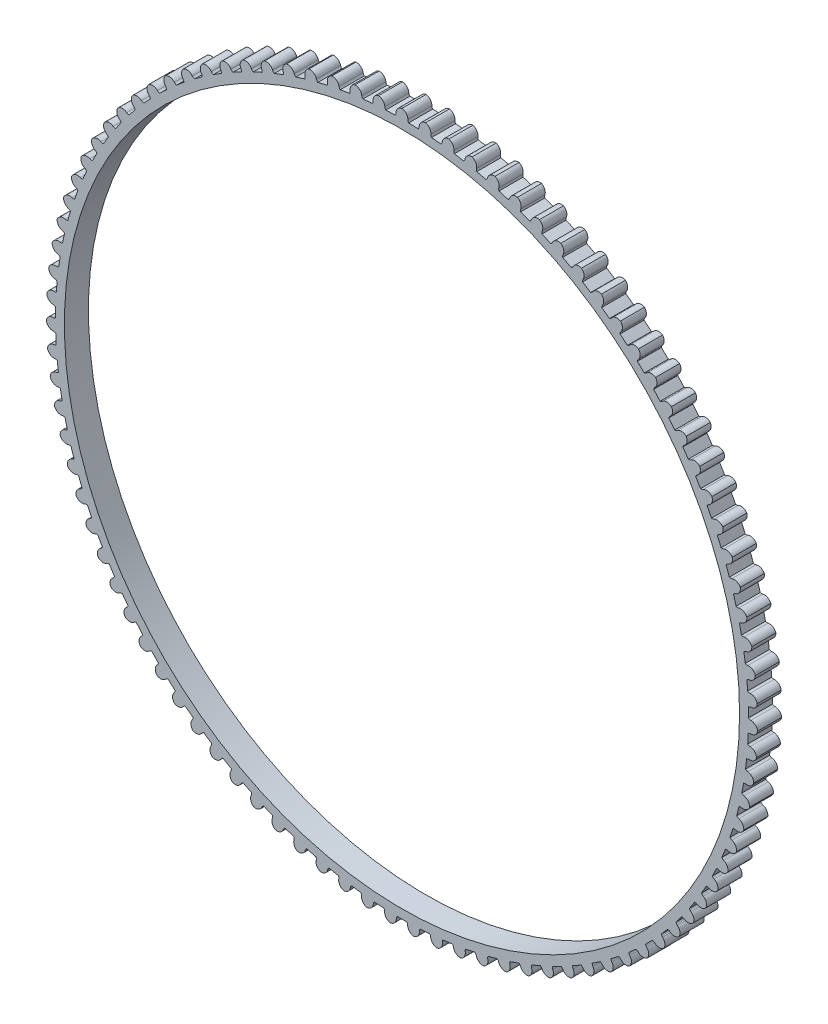
from build123d import *

# Parameters (mm, degrees)
SKETCH1_R      = 44.577
EXTRUDE1_DEPTH = 3.175


with BuildPart() as part:
    # Sketch1 → Extrude1 (new body)
    with BuildSketch(Plane.XY):
        with BuildLine():
            ThreePointArc((1.512467656, 45.720390011), (1.196213111, 45.729757219), (0.879901343, 45.736936876))
            ThreePointArc((0.879901343, 45.736936876), (0.802731173, 45.892155239), (0.777675809, 46.063678427))
            ThreePointArc((0.777675809, 46.063678427), (0.559737338, 46.661659663), (0, 46.9646))
            ThreePointArc((0, 46.9646), (-0.559737396, 46.661659691), (-0.777675895, 46.063678426))
            ThreePointArc((-0.777675895, 46.063678426), (-0.802731266, 45.892155234), (-0.879901451, 45.736936874))
            ThreePointArc((-0.879901451, 45.736936874), (-1.196213165, 45.729757218), (-1.512467656, 45.720390011))
            ThreePointArc((-1.512467656, 45.720390011), (-1.828679241, 45.708834522), (-2.144803332, 45.695092076))
            ThreePointArc((-2.144803332, 45.695092076), (-2.232063251, 45.844870852), (-2.268399903, 46.014363103))
            ThreePointArc((-2.268399903, 46.014363103), (-2.525382809, 46.596633248), (-3.103917856, 46.861917877))
            ThreePointArc((-3.103917856, 46.861917877), (-3.642409955, 46.522646537), (-3.820351029, 45.911568999))
            ThreePointArc((-3.820351029, 45.911568999), (-3.834015551, 45.738764897), (-3.900758541, 45.578785679))
            ThreePointArc((-3.900758541, 45.578785679), (-4.215933462, 45.550713784), (-4.53090667, 45.520462497))
            ThreePointArc((-4.53090667, 45.520462497), (-4.845633899, 45.488036375), (-5.160129329, 45.453434265))
            ThreePointArc((-5.160129329, 45.453434265), (-5.257097432, 45.59711851), (-5.304556481, 45.763838676))
            ThreePointArc((-5.304556481, 45.763838676), (-5.5994601, 46.327851612), (-6.19426307, 46.55432051))
            ThreePointArc((-6.19426307, 46.55432051), (-6.709155184, 46.180201686), (-6.84632074, 45.558699963))
            ThreePointArc((-6.84632074, 45.558699963), (-6.848534662, 45.385370578), (-6.904558608, 45.221330051))
            ThreePointArc((-6.904558608, 45.221330051), (-7.21718915, 45.172489437), (-7.529474384, 45.121487527))
            ThreePointArc((-7.529474384, 45.121487527), (-7.84137044, 45.068331795), (-8.152891393, 45.013020151))
            ThreePointArc((-8.152891393, 45.013020151), (-8.259143664, 45.14998157), (-8.317517582, 45.313200628))
            ThreePointArc((-8.317517582, 45.313200628), (-8.649052376, 45.856490068), (-9.257522347, 46.043152945))
            ThreePointArc((-9.257522347, 46.043152945), (-9.746562983, 45.635822564), (-9.842353232, 45.006614323))
            ThreePointArc((-9.842353232, 45.006614323), (-9.833106874, 44.833517582), (-9.878166796, 44.666133053))
            ThreePointArc((-9.878166796, 44.666133053), (-10.186885907, 44.596737287), (-10.495117623, 44.525207773))
            ThreePointArc((-10.495117623, 44.525207773), (-10.802818664, 44.451554867), (-11.110002937, 44.375775553))
            ThreePointArc((-11.110002937, 44.375775553), (-11.225074761, 44.505415248), (-11.294108295, 44.664419482))
            ThreePointArc((-11.294108295, 44.664419482), (-11.660824547, 45.184609761), (-12.280300835, 45.330650388))
            ThreePointArc((-12.280300835, 45.330650388), (-12.741351542, 44.891889601), (-12.795347618, 44.25772621))
            ThreePointArc((-12.795347618, 44.25772621), (-12.774681411, 44.08561902), (-12.808580274, 43.91562242))
            ThreePointArc((-12.808580274, 43.91562242), (-13.112038003, 43.825974953), (-13.414868382, 43.734230615))
            ThreePointArc((-13.414868382, 43.734230615), (-13.717028911, 43.640402599), (-14.018533265, 43.544486979))
            ThreePointArc((-14.018533265, 43.544486979), (-14.141921462, 43.66623807), (-14.221312746, 43.820332194))
            ThreePointArc((-14.221312746, 43.820332194), (-14.6216069, 44.315148652), (-15.249380691, 44.41992843))
            ThreePointArc((-15.249380691, 44.41992843), (-15.680425414, 43.951655827), (-15.692391205, 43.315310321))
            ThreePointArc((-15.692391205, 43.315310321), (-15.660395517, 43.144945264), (-15.682985089, 42.973079944))
            ThreePointArc((-15.682985089, 42.973079944), (-15.979854493, 42.863572781), (-16.275959335, 42.752014793))
            ThreePointArc((-16.275959335, 42.752014793), (-16.57125808, 42.638421955), (-16.865764114, 42.522789443))
            ThreePointArc((-16.865764114, 42.522789443), (-16.99692914, 42.636119542), (-17.086331015, 42.784629744))
            ThreePointArc((-17.086331015, 42.784629744), (-17.518452685, 43.251908673), (-18.151778886, 43.314969427))
            ThreePointArc((-18.151778886, 43.314969427), (-18.550932774, 42.819232645), (-18.520815957, 42.183487602))
            ThreePointArc((-18.520815957, 42.183487602), (-18.477630697, 42.015609639), (-18.488812201, 41.842627123))
            ThreePointArc((-18.488812201, 41.842627123), (-18.777795146, 41.713739111), (-19.06587966, 41.582855289))
            ThreePointArc((-19.06587966, 41.582855289), (-19.353025355, 41.44999434), (-19.639245268, 41.315150568))
            ThreePointArc((-19.639245268, 41.315150568), (-19.77761357, 41.419564113), (-19.876635106, 41.561840993))
            ThreePointArc((-19.876635106, 41.561840993), (-20.338694734, 41.999539103), (-20.97480397, 42.020605083))
            ThreePointArc((-20.97480397, 42.020605083), (-21.340321625, 41.499571853), (-21.268253894, 40.867207224))
            ThreePointArc((-21.268253894, 40.867207224), (-21.2140679, 40.702550444), (-21.213792442, 40.52920714))
            ThreePointArc((-21.213792442, 40.52920714), (-21.493625278, 40.381501874), (-21.772429743, 40.231864538))
            ThreePointArc((-21.772429743, 40.231864538), (-22.050166773, 40.080316446), (-22.326849, 39.926851052))
            ThreePointArc((-22.326849, 39.926851052), (-22.471815529, 40.021891468), (-22.580023729, 40.157312886))
            ThreePointArc((-22.580023729, 40.157312886), (-23.070000847, 40.563516234), (-23.706111573, 40.542495326))
            ThreePointArc((-23.706111573, 40.542495326), (-24.03639468, 39.998443993), (-23.922691168, 39.372224947))
            ThreePointArc((-23.922691168, 39.372224947), (-23.857741382, 39.211509352), (-23.846010165, 39.038563246))
            ThreePointArc((-23.846010165, 39.038563246), (-24.115469255, 38.872686603), (-24.383774531, 38.704950081))
            ThreePointArc((-24.383774531, 38.704950081), (-24.650888422, 38.535377527), (-24.916823101, 38.363961575))
            ThreePointArc((-24.916823101, 38.363961575), (-25.067753956, 38.449213274), (-25.184675654, 38.577187068))
            ThreePointArc((-25.184675654, 38.577187068), (-25.700427715, 38.95011943), (-26.333758382, 38.887103551))
            ThreePointArc((-26.333758382, 38.887103551), (-26.627362697, 38.322413114), (-26.4725206, 37.705077948))
            ThreePointArc((-26.4725206, 37.705077948), (-26.397091031, 37.549006307), (-26.373955354, 37.377213649))
            ThreePointArc((-26.373955354, 37.377213649), (-26.631862422, 37.193890965), (-26.888495277, 37.008788725))
            ThreePointArc((-26.888495277, 37.008788725), (-27.143818009, 36.821933206), (-27.397842275, 36.633316255))
            ThreePointArc((-27.397842275, 36.633316255), (-27.554077473, 36.708406454), (-27.679201399, 36.828373026))
            ThreePointArc((-27.679201399, 36.828373026), (-28.218473152, 37.166403664), (-28.846254366, 37.061668368))
            ThreePointArc((-28.846254366, 37.061668368), (-29.101896031, 36.478808074), (-28.906592435, 35.873056237))
            ThreePointArc((-28.906592435, 35.873056237), (-28.821012918, 35.722311011), (-28.786573946, 35.552423006))
            ThreePointArc((-28.786573946, 35.552423006), (-29.03180123, 35.352455905), (-29.275639475, 35.150797352))
            ThreePointArc((-29.275639475, 35.150797352), (-29.518054586, 34.947475941), (-29.759057655, 34.742482764))
            ThreePointArc((-29.759057655, 34.742482764), (-29.919914021, 34.807083113), (-30.05269304, 34.91851788))
            ThreePointArc((-30.05269304, 34.91851788), (-30.613126386, 35.220168671), (-31.232613019, 35.074171938))
            ThreePointArc((-31.232613019, 35.074171938), (-31.449174179, 34.475690487), (-31.214263096, 33.884170778))
            ThreePointArc((-31.214263096, 33.884170778), (-31.118907847, 33.739411138), (-31.073316175, 33.572170663))
            ThreePointArc((-31.073316175, 33.572170663), (-31.304791358, 33.35643355), (-31.53476875, 33.139100486))
            ThreePointArc((-31.53476875, 33.139100486), (-31.76321622, 32.920202255), (-31.990144248, 32.699729236))
            ThreePointArc((-31.990144248, 32.699729236), (-32.154918396, 32.753557253), (-32.2947719, 32.855972939))
            ThreePointArc((-32.2947719, 32.855972939), (-32.873916207, 33.119924842), (-33.482399403, 32.933305079))
            ThreePointArc((-33.482399403, 32.933305079), (-33.65893309, 32.321819478), (-33.385441727, 31.747118462))
            ThreePointArc((-33.385441727, 31.747118462), (-33.280727711, 31.608977404), (-33.224182699, 31.44511576))
            ThreePointArc((-33.224182699, 31.44511576), (-33.440893599, 31.214551999), (-33.656004506, 30.982494765))
            ThreePointArc((-33.656004506, 30.982494765), (-33.869485392, 30.748976901), (-34.08134608, 30.513988112))
            ThreePointArc((-34.08134608, 30.513988112), (-34.249317496, 30.556808421), (-34.39563394, 30.649757189))
            ThreePointArc((-34.39563394, 30.649757189), (-34.990956757, 30.874856009), (-35.585775772, 30.648429256))
            ThreePointArc((-35.585775772, 30.648429256), (-35.72151005, 30.026613376), (-35.410634316, 29.471244075))
            ThreePointArc((-35.410634316, 29.471244075), (-35.297019421, 29.340325655), (-35.229768325, 29.180559366))
            ThreePointArc((-35.229768325, 29.180559366), (-35.43076732, 28.936177154), (-35.630071116, 28.690410478))
            ThreePointArc((-35.630071116, 28.690410478), (-35.827651922, 28.443294094), (-36.023518857, 28.194817082))
            ThreePointArc((-36.023518857, 28.194817082), (-36.193953044, 28.226442441), (-36.346092624, 28.309517849))
            ThreePointArc((-36.346092624, 28.309517849), (-36.954990756, 28.494779286), (-37.533544599, 28.22953565))
            ThreePointArc((-37.533544599, 28.22953565), (-37.627885936, 27.600108533), (-37.28098521, 27.066499436))
            ThreePointArc((-37.28098521, 27.066499436), (-37.158966245, 26.943376127), (-37.081303138, 26.788403811))
            ThreePointArc((-37.081303138, 26.788403811), (-37.265711311, 26.531271768), (-37.448336492, 26.272870326))
            ThreePointArc((-37.448336492, 26.272870326), (-37.629153246, 26.013236), (-37.808169952, 25.752357291))
            ThreePointArc((-37.808169952, 25.752357291), (-37.980321644, 25.77264941), (-38.137619093, 25.84548819))
            ThreePointArc((-38.137619093, 25.84548819), (-38.757429984, 25.990102143), (-39.317188785, 25.687201467))
            ThreePointArc((-39.317188785, 25.687201467), (-39.369724651, 25.052915439), (-38.988315842, 24.543399881))
            ThreePointArc((-38.988315842, 24.543399881), (-38.858426365, 24.428610071), (-38.770690847, 24.279109382))
            ThreePointArc((-38.770690847, 24.279109382), (-38.937701828, 24.010351882), (-39.10284982, 23.740445597))
            ThreePointArc((-39.10284982, 23.740445597), (-39.266111857, 23.469428643), (-39.427495539, 23.197288993))
            ThreePointArc((-39.427495539, 23.197288993), (-39.600611962, 23.20615914), (-39.762379458, 23.268442787))
            ThreePointArc((-39.762379458, 23.268442787), (-40.390392831, 23.371776897), (-40.928908908, 23.032543688))
            ThreePointArc((-40.928908908, 23.032543688), (-40.939409577, 22.396172319), (-40.525160489, 21.912978284))
            ThreePointArc((-40.525160489, 21.912978284), (-40.387968473, 21.807023919), (-40.29054419, 21.663648586))
            ThreePointArc((-40.29054419, 21.663648586), (-40.439427683, 21.384440836), (-40.586376335, 21.104209939))
            ThreePointArc((-40.586376335, 21.104209939), (-40.731369751, 20.822995446), (-40.874414721, 20.540784854))
            ThreePointArc((-40.874414721, 20.540784854), (-41.047738879, 20.538194241), (-41.213269054, 20.589650405))
            ThreePointArc((-41.213269054, 20.589650405), (-41.846738767, 20.651252817), (-42.361657327, 20.277170456))
            ThreePointArc((-42.361657327, 20.277170456), (-42.330076882, 19.641496437), (-41.884798921, 19.186736808))
            ThreePointArc((-41.884798921, 19.186736808), (-41.740904271, 19.090081199), (-41.634217234, 18.953458166))
            ThreePointArc((-41.634217234, 18.953458166), (-41.764322209, 18.665021071), (-41.892428953, 18.375690941))
            ThreePointArc((-41.892428953, 18.375690941), (-42.018519729, 18.085508588), (-42.142600486, 17.794461088))
            ThreePointArc((-42.142600486, 17.794461088), (-42.315374479, 17.780421045), (-42.48394351, 17.82082472))
            ThreePointArc((-42.48394351, 17.82082472), (-43.120099562, 17.840426062), (-43.609168996, 17.433130317))
            ThreePointArc((-43.609168996, 17.433130317), (-43.53564553, 16.800933288), (-43.061285783, 16.376596614))
            ThreePointArc((-43.061285783, 16.376596614), (-42.911317715, 16.289662411), (-42.79583444, 16.160389096))
            ThreePointArc((-42.79583444, 16.160389096), (-42.906591981, 15.863983918), (-43.015296638, 15.566819723))
            ThreePointArc((-43.015296638, 15.566819723), (-43.121933412, 15.268938403), (-43.226507383, 14.970326671))
            ThreePointArc((-43.226507383, 14.970326671), (-43.397975712, 14.944898591), (-43.568846491, 14.974073103))
            ThreePointArc((-43.568846491, 14.974073103), (-44.204907133, 14.951587664), (-44.665988865, 14.512859534))
            ThreePointArc((-44.665988865, 14.512859534), (-44.550843878, 13.886903933), (-44.0494766, 13.494845729))
            ThreePointArc((-44.0494766, 13.494845729), (-43.894090885, 13.418013075), (-43.770316351, 13.296654756))
            ThreePointArc((-43.770316351, 13.296654756), (-43.861242143, 12.9935776), (-43.950069376, 12.689878762))
            ThreePointArc((-43.950069376, 12.689878762), (-44.036785852, 12.385601036), (-44.121395761, 12.080730825))
            ThreePointArc((-44.121395761, 12.080730825), (-44.29080864, 12.044025898), (-44.463233992, 12.061843674))
            ThreePointArc((-44.463233992, 12.061843674), (-45.096417893, 11.997369777), (-45.52749573, 11.529127709))
            ThreePointArc((-45.52749573, 11.529127709), (-45.371232721, 10.91215068), (-44.845050263, 10.554085318))
            ThreePointArc((-44.845050263, 10.554085318), (-44.684926364, 10.487690181), (-44.553401805, 10.374777528))
            ThreePointArc((-44.553401805, 10.374777528), (-44.624098253, 10.066353674), (-44.692659643, 9.75744819))
            ThreePointArc((-44.692659643, 9.75744819), (-44.759076631, 9.448104586), (-44.823352501, 9.138309017))
            ThreePointArc((-44.823352501, 9.138309017), (-44.989969131, 9.090487744), (-45.163195084, 9.096870872))
            ThreePointArc((-45.163195084, 9.096870872), (-45.790733491, 8.990690445), (-46.189922439, 8.494981943))
            ThreePointArc((-46.189922439, 8.494981943), (-45.993224707, 7.889681369), (-45.444527931, 7.567174577))
            ThreePointArc((-45.444527931, 7.567174577), (-45.28036603, 7.511507287), (-45.141666569, 7.407534038))
            ThreePointArc((-45.141666569, 7.407534038), (-45.191824535, 7.095112143), (-45.239820281, 6.78235078))
            ThreePointArc((-45.239820281, 6.78235078), (-45.285647357, 6.469293979), (-45.329308126, 6.155927709))
            ThreePointArc((-45.329308126, 6.155927709), (-45.492399934, 6.097199201), (-45.665669015, 6.092119768))
            ThreePointArc((-45.665669015, 6.092119768), (-46.284817863, 5.944697111), (-46.650372371, 5.423689781))
            ThreePointArc((-46.650372371, 5.423689781), (-46.414100025, 4.832712488), (-45.845288242, 4.547174508))
            ThreePointArc((-45.845288242, 4.547174508), (-45.677806176, 4.502478482), (-45.532538311, 4.407899286))
            ThreePointArc((-45.532538311, 4.407899286), (-45.561938468, 4.092845493), (-45.589158695, 3.777595876))
            ThreePointArc((-45.589158695, 3.777595876), (-45.61419547, 3.462194795), (-45.63705022, 3.146628095))
            ThreePointArc((-45.63705022, 3.146628095), (-45.795904047, 3.077249156), (-45.968458595, 3.060729374))
            ThreePointArc((-45.968458595, 3.060729374), (-46.576510503, 2.872709129), (-46.906832093, 2.328681205))
            ThreePointArc((-46.906832093, 2.328681205), (-46.632018292, 1.754611385), (-46.045578771, 1.507290801))
            ThreePointArc((-46.045578771, 1.507290801), (-45.875508898, 1.473761485), (-45.724307848, 1.388989913))
            ThreePointArc((-45.724307848, 1.388989913), (-45.732821636, 1.072681871), (-45.739147319, 0.756322506))
            ThreePointArc((-45.739147319, 0.756322506), (-45.743284311, 0.439956314), (-45.745233105, 0.123569077))
            ThreePointArc((-45.745233105, 0.123569077), (-45.899154323, 0.043843084), (-46.070239801, 0.015955189))
            ThreePointArc((-46.070239801, 0.015955189), (-46.664535913, -0.211840479), (-46.958180174, -0.776510102))
            ThreePointArc((-46.958180174, -0.776510102), (-46.646026608, -1.331162186), (-46.044523701, -1.539183906))
            ThreePointArc((-46.044523701, -1.539183906), (-45.872609691, -1.561399896), (-45.716136621, -1.635993161))
            ThreePointArc((-45.716136621, -1.635993161), (-45.703726811, -1.952172317), (-45.689130288, -2.26825807))
            ThreePointArc((-45.689130288, -2.26825807), (-45.67234941, -2.584205983), (-45.653383725, -2.900030277))
            ThreePointArc((-45.653383725, -2.900030277), (-45.801699277, -2.989754702), (-45.97056757, -3.028888763))
            ThreePointArc((-45.97056757, -3.028888763), (-46.548509181, -3.295463763), (-46.80419208, -3.878305928))
            ThreePointArc((-46.80419208, -3.878305928), (-46.456063718, -4.411114925), (-45.842127644, -4.578928152))
            ThreePointArc((-45.842127644, -4.578928152), (-45.669121235, -4.589733673), (-45.50806036, -4.653822452))
            ThreePointArc((-45.50806036, -4.653822452), (-45.474781218, -4.968490151), (-45.439326316, -5.28292013))
            ThreePointArc((-45.439326316, -5.28292013), (-45.401700945, -5.597068206), (-45.361903714, -5.910948537))
            ThreePointArc((-45.361903714, -5.910948537), (-45.503965053, -6.010279052), (-45.669877744, -6.060488156))
            ThreePointArc((-45.669877744, -6.060488156), (-46.228937662, -6.364676822), (-46.445541164, -6.963142909))
            ThreePointArc((-46.445541164, -6.963142909), (-46.062960282, -7.47177898), (-45.439275627, -7.598649911))
            ThreePointArc((-45.439275627, -7.598649911), (-45.265933331, -7.597997712), (-45.10098893, -7.651301762))
            ThreePointArc((-45.10098893, -7.651301762), (-45.046985976, -7.963082042), (-44.990827731, -8.274481325))
            ThreePointArc((-44.990827731, -8.274481325), (-44.932522393, -8.585455873), (-44.87206764, -8.896019722))
            ThreePointArc((-44.87206764, -8.896019722), (-45.007253568, -9.004521981), (-45.169485163, -9.065586575))
            ThreePointArc((-45.169485163, -9.065586575), (-45.70721876, -9.406058768), (-45.883795713, -10.017531838))
            ThreePointArc((-45.883795713, -10.017531838), (-45.468435241, -10.499770846), (-44.837729219, -10.585144707))
            ThreePointArc((-44.837729219, -10.585144707), (-44.664809018, -10.573037641), (-44.496702352, -10.615323876))
            ThreePointArc((-44.496702352, -10.615323876), (-44.422211727, -10.922853402), (-44.345595705, -11.229860318))
            ThreePointArc((-44.345595705, -11.229860318), (-44.266865354, -11.536301526), (-44.186017431, -11.842190877))
            ThreePointArc((-44.186017431, -11.842190877), (-44.313736814, -11.959390427), (-44.471577916, -12.031043492))
            ThreePointArc((-44.471577916, -12.031043492), (-44.985633821, -12.406310413), (-45.121412098, -13.028116649))
            ThreePointArc((-45.121412098, -13.028116649), (-44.675088301, -13.481849886), (-44.040118829, -13.525353359))
            ThreePointArc((-44.040118829, -13.525353359), (-43.868376859, -13.501844366), (-43.697843015, -13.53292788))
            ThreePointArc((-43.697843015, -13.53292788), (-43.603190449, -13.834861902), (-43.506451671, -14.13613399))
            ThreePointArc((-43.506451671, -14.13613399), (-43.407640576, -14.436701868), (-43.30675301, -14.736579145))
            ThreePointArc((-43.30675301, -14.736579145), (-43.426447365, -14.861963501), (-43.579207774, -14.943891716))
            ThreePointArc((-43.579207774, -14.943891716), (-44.067338151, -15.352312419), (-44.161724029, -15.98173282))
            ThreePointArc((-44.161724029, -15.98173282), (-43.686388567, -16.404976227), (-43.049932205, -16.406419082))
            ThreePointArc((-43.049932205, -16.406419082), (-42.880119451, -16.371610961), (-42.707904129, -16.391355834))
            ThreePointArc((-42.707904129, -16.391355834), (-42.593503513, -16.686374072), (-42.477064994, -16.980593944))
            ThreePointArc((-42.477064994, -16.980593944), (-42.35860523, -17.273974186), (-42.238119177, -17.566528101))
            ThreePointArc((-42.238119177, -17.566528101), (-42.34926511, -17.69954899), (-42.496276845, -17.791394104))
            ThreePointArc((-42.496276845, -17.791394104), (-42.956347224, -18.231182669), (-43.008927977, -18.865464941))
            ThreePointArc((-43.008927977, -18.865464941), (-42.506659372, -19.256367781), (-41.871499181, -19.215743708))
            ThreePointArc((-41.871499181, -19.215743708), (-41.70435819, -19.169788667), (-41.531214445, -19.178108559))
            ThreePointArc((-41.531214445, -19.178108559), (-41.397566023, -19.464920973), (-41.261936919, -19.750802082))
            ThreePointArc((-41.261936919, -19.750802082), (-41.12434648, -20.03571181), (-40.984788797, -20.319663099))
            ThreePointArc((-40.984788797, -20.319663099), (-41.086900295, -20.459738855), (-41.22752051, -20.561099253))
            ThreePointArc((-41.22752051, -20.561099253), (-41.65751912, -21.030332596), (-41.668064826, -21.666703183))
            ThreePointArc((-41.668064826, -21.666703183), (-41.14105937, -22.023556139), (-40.509972745, -21.941042777))
            ThreePointArc((-40.509972745, -21.941042777), (-40.346234382, -21.884141764), (-40.172919327, -21.881000294))
            ThreePointArc((-40.172919327, -21.881000294), (-40.020607511, -22.158352728), (-39.866380893, -22.434644987))
            ThreePointArc((-39.866380893, -22.434644987), (-39.710261428, -22.709838364), (-39.552242362, -22.983945381))
            ThreePointArc((-39.552242362, -22.983945381), (-39.644872918, -23.130463487), (-39.778486717, -23.240895946))
            ThreePointArc((-39.778486717, -23.240895946), (-40.176533284, -23.73752223), (-40.14499783, -24.373198445))
            ThreePointArc((-40.14499783, -24.373198445), (-39.595559984, -24.694441089), (-38.971306506, -24.570399248))
            ThreePointArc((-38.971306506, -24.570399248), (-38.811686756, -24.502801078), (-38.638958255, -24.488211983))
            ThreePointArc((-38.638958255, -24.488211983), (-38.468649064, -24.754891644), (-38.296499326, -25.020386898))
            ThreePointArc((-38.296499326, -25.020386898), (-38.122533506, -25.284660573), (-37.946744036, -25.547724717))
            ThreePointArc((-37.946744036, -25.547724717), (-38.029488599, -25.700044488), (-38.155511723, -25.819066114))
            ThreePointArc((-38.155511723, -25.819066114), (-38.519865691, -26.340913718), (-38.446386972, -26.973115911))
            ThreePointArc((-38.446386972, -26.973115911), (-37.876919288, -27.257343531), (-37.262228659, -27.092315614))
            ThreePointArc((-37.262228659, -27.092315614), (-37.1074255, -27.014315877), (-36.936038849, -26.988342952))
            ThreePointArc((-36.936038849, -26.988342952), (-36.748477003, -27.243183718), (-36.559156912, -27.496721023))
            ThreePointArc((-36.559156912, -27.496721023), (-36.368105444, -27.748919394), (-36.175314253, -27.999790354))
            ThreePointArc((-36.175314253, -27.999790354), (-36.247811003, -28.157245733), (-36.365692385, -28.284336076))
            ThreePointArc((-36.365692385, -28.284336076), (-36.694760526, -28.829123093), (-36.579659846, -29.455086805))
            ThreePointArc((-36.579659846, -29.455086805), (-35.992652461, -29.701056545), (-35.390212566, -29.495764178))
            ThreePointArc((-35.390212566, -29.495764178), (-35.240902913, -29.407703946), (-35.071607543, -29.370460764))
            ThreePointArc((-35.071607543, -29.370460764), (-34.867613203, -29.612348281), (-34.661950607, -29.852818983))
            ThreePointArc((-34.661950607, -29.852818983), (-34.454648911, -30.091839252), (-34.245699025, -30.329420032))
            ThreePointArc((-34.245699025, -30.329420032), (-34.307630952, -30.491322507), (-34.416855126, -30.625925833))
            ThreePointArc((-34.416855126, -30.625925833), (-34.709198509, -31.191270048), (-34.552979175, -31.808258099))
            ThreePointArc((-34.552979175, -31.808258099), (-33.950998923, -32.014894396), (-33.363444079, -31.77023527))
            ThreePointArc((-33.363444079, -31.77023527), (-33.220280825, -31.672499608), (-33.053817022, -31.624149024))
            ThreePointArc((-33.053817022, -31.624149024), (-32.834282201, -31.852025579), (-32.613176412, -32.078378162))
            ThreePointArc((-32.613176412, -32.078378162), (-32.390530965, -32.303175153), (-32.166336069, -32.526426872))
            ThreePointArc((-32.166336069, -32.526426872), (-32.21743236, -32.692068486), (-32.317521717, -32.833596208))
            ThreePointArc((-32.317521717, -32.833596208), (-32.571861999, -33.417025515), (-32.375207118, -34.022339973))
            ThreePointArc((-32.375207118, -34.022339973), (-31.760886306, -34.18873926), (-31.19078574, -33.905783207))
            ThreePointArc((-31.19078574, -33.905783207), (-31.054394901, -33.798799489), (-30.891490568, -33.739552926))
            ThreePointArc((-30.891490568, -33.739552926), (-30.657375238, -33.952422074), (-30.421793093, -34.163666755))
            ThreePointArc((-30.421793093, -34.163666755), (-30.184777468, -34.373257488), (-29.946317909, -34.581203924))
            ThreePointArc((-29.946317909, -34.581203924), (-29.986355134, -34.749860368), (-30.076872008, -34.897693621))
            ThreePointArc((-30.076872008, -34.897693621), (-30.292097024, -35.496656832), (-30.055866517, -36.087650811))
            ThreePointArc((-30.055866517, -36.087650811), (-29.431891413, -36.213085465), (-28.881738031, -35.893069781))
            ThreePointArc((-28.881738031, -35.893069781), (-28.75271601, -35.777305818), (-28.594083486, -35.707422348))
            ThreePointArc((-28.594083486, -35.707422348), (-28.346411373, -35.904353266), (-28.097383014, -36.099566326))
            ThreePointArc((-28.097383014, -36.099566326), (-27.84703362, -36.293034314), (-27.595352121, -36.48476617))
            ThreePointArc((-27.595352121, -36.48476617), (-27.624155207, -36.655699951), (-27.704703791, -36.809192299))
            ThreePointArc((-27.704703791, -36.809192299), (-27.879872416, -37.4210703), (-27.60509926, -37.995159534))
            ThreePointArc((-27.60509926, -37.995159534), (-26.974198349, -38.079081062), (-26.44639783, -37.723405093))
            ThreePointArc((-26.44639783, -37.723405093), (-26.325308807, -37.599367093), (-26.171641752, -37.519152298))
            ThreePointArc((-26.171641752, -37.519152298), (-25.911495863, -37.699283856), (-25.650110229, -37.877611678))
            ThreePointArc((-25.650110229, -37.877611678), (-25.387521779, -38.054110935), (-25.123718879, -38.228789817))
            ThreePointArc((-25.123718879, -38.228789817), (-25.141161877, -38.401253486), (-25.211389953, -38.559733745))
            ThreePointArc((-25.211389953, -38.559733745), (-25.345736219, -39.18185095), (-25.033621927, -39.736525092))
            ThreePointArc((-25.033621927, -39.736525092), (-24.398553977, -39.778566526), (-23.89541426, -39.388785552))
            ThreePointArc((-23.89541426, -39.388785552), (-23.782787727, -39.257015901), (-23.634758088, -39.166820541))
            ThreePointArc((-23.634758088, -39.166820541), (-23.363275975, -39.329365071), (-23.090676037, -39.490027872))
            ThreePointArc((-23.090676037, -39.490027872), (-22.816996765, -39.648786612), (-22.542226006, -39.805648693))
            ThreePointArc((-22.542226006, -39.805648693), (-22.548232643, -39.97888811), (-22.607833122, -40.141663287))
            ThreePointArc((-22.607833122, -40.141663287), (-22.700769567, -40.771299334), (-22.352678935, -41.304132936))
            ThreePointArc((-22.352678935, -41.304132936), (-21.716220938, -41.30411044), (-21.239942124, -40.881928875))
            ThreePointArc((-21.239942124, -40.881928875), (-21.136270567, -40.743003768), (-20.994525641, -40.643222243))
            ThreePointArc((-20.994525641, -40.643222243), (-20.712894426, -40.787468978), (-20.430272195, -40.929764221))
            ThreePointArc((-20.430272195, -40.929764221), (-20.146698829, -41.070088233), (-19.862161715, -41.208447595))
            ThreePointArc((-19.862161715, -41.208447595), (-19.856705725, -41.381705228), (-19.905417988, -41.548063548))
            ThreePointArc((-19.905417988, -41.548063548), (-19.956538226, -42.182465201), (-19.573993365, -42.691128316))
            ThreePointArc((-19.573993365, -42.691128316), (-18.938928389, -42.649041989), (-18.491593125, -42.196305924))
            ThreePointArc((-18.491593125, -42.196305924), (-18.397329874, -42.050832846), (-18.262489475, -41.941901475))
            ThreePointArc((-18.262489475, -41.941901475), (-17.971940659, -42.067219662), (-17.68053197, -42.190525126))
            ThreePointArc((-17.68053197, -42.190525126), (-17.388304505, -42.311800808), (-17.095245245, -42.43105244))
            ThreePointArc((-17.095245245, -42.43105244), (-17.078350485, -42.603570678), (-17.115961527, -42.772784699))
            ThreePointArc((-17.115961527, -42.772784699), (-17.125042021, -43.409177879), (-16.709715703, -43.891446254))
            ThreePointArc((-16.709715703, -43.891446254), (-16.078820726, -43.807480128), (-15.662385094, -43.326169264))
            ThreePointArc((-15.662385094, -43.326169264), (-15.577942339, -43.174784331), (-15.450596089, -43.057179444))
            ThreePointArc((-15.450596089, -43.057179444), (-15.152400169, -43.163021098), (-14.853479277, -43.2667976))
            ThreePointArc((-14.853479277, -43.2667976), (-14.55387555, -43.368494643), (-14.253575617, -43.468117089))
            ThreePointArc((-14.253575617, -43.468117089), (-14.225315964, -43.639141554), (-14.25166132, -43.810471345))
            ThreePointArc((-14.25166132, -43.810471345), (-14.218662364, -44.446073268), (-13.772370706, -44.899838065))
            ThreePointArc((-13.772370706, -44.899838065), (-13.14840447, -44.774359303), (-12.764689438, -44.26657829))
            ThreePointArc((-12.764689438, -44.26657829), (-12.690436425, -44.109943469), (-12.571141177, -43.984179323))
            ThreePointArc((-12.571141177, -43.984179323), (-12.266602088, -44.070081624), (-11.961476099, -44.153875376))
            ThreePointArc((-11.961476099, -44.153875376), (-11.655806201, -44.235549086), (-11.349578729, -44.315106723))
            ThreePointArc((-11.349578729, -44.315106723), (-11.310077756, -44.483889567), (-11.325042225, -44.656585947))
            ThreePointArc((-11.325042225, -44.656585947), (-11.250108114, -45.288617287), (-10.774802635, -45.711894309))
            ThreePointArc((-10.774802635, -45.711894309), (-10.160493588, -45.545451597), (-9.811177043, -45.013420832))
            ThreePointArc((-9.811177043, -45.013420832), (-9.747438462, -44.852221048), (-9.636715863, -44.718847576))
            ThreePointArc((-9.636715863, -44.718847576), (-9.327165278, -44.784434897), (-9.01716843, -44.847879489))
            ThreePointArc((-9.01716843, -44.847879489), (-8.706768976, -44.909172729), (-8.395953021, -44.96831767))
            ThreePointArc((-8.395953021, -44.96831767), (-8.345383455, -45.134120849), (-8.348901602, -45.307428662))
            ThreePointArc((-8.348901602, -45.307428662), (-8.232360004, -45.933125706), (-7.730119095, -46.32406407))
            ThreePointArc((-7.730119095, -46.32406407), (-7.128153452, -46.117385219), (-6.814762868, -45.563431137))
            ThreePointArc((-6.814762868, -45.563431137), (-6.76181743, -45.398371277), (-6.660151644, -45.257971687))
            ThreePointArc((-6.660151644, -45.257971687), (-6.346943146, -45.302957231), (-6.033430977, -45.345775237))
            ThreePointArc((-6.033430977, -45.345775237), (-5.719659266, -45.386419985), (-5.405613947, -45.424893605))
            ThreePointArc((-5.405613947, -45.424893605), (-5.344196916, -45.586992105), (-5.336253356, -45.760153518))
            ThreePointArc((-5.336253356, -45.760153518), (-5.178613878, -46.376780253), (-4.65163371, -46.733670485))
            ThreePointArc((-4.65163371, -46.733670485), (-4.064643714, -46.48765925), (-3.788549468, -45.914204152))
            ThreePointArc((-3.788549468, -45.914204152), (-3.746628692, -45.746005979), (-3.654464275, -45.599194204))
            ThreePointArc((-3.654464275, -45.599194204), (-3.338967447, -45.623381259), (-3.023310865, -45.645385447))
            ThreePointArc((-3.023310865, -45.645385447), (-2.707538942, -45.665203975), (-2.391637499, -45.682838038))
            ThreePointArc((-2.391637499, -45.682838038), (-2.319641564, -45.840523043), (-2.300271032, -46.012780866))
            ThreePointArc((-2.300271032, -46.012780866), (-2.102222992, -46.61764094), (-1.552807915, -46.93892245))
            ThreePointArc((-1.552807915, -46.93892245), (-0.983360324, -46.654654576), (-0.745769705, -46.064206034))
            ThreePointArc((-0.745769705, -46.064206034), (-0.715056899, -45.893605036), (-0.632796864, -45.741023046))
            ThreePointArc((-0.632796864, -45.741023046), (-0.316391293, -45.74430585), (2.9415e-05, -45.7454))
            ThreePointArc((2.9415e-05, -45.7454), (0.316420762, -45.744305646), (0.632796972, -45.741023044))
            ThreePointArc((0.632796972, -45.741023044), (0.715056991, -45.893605037), (0.745769792, -46.064206031))
            ThreePointArc((0.745769792, -46.064206031), (0.983360381, -46.654654545), (1.552807915, -46.93892245))
            ThreePointArc((1.552807915, -46.93892245), (2.102223051, -46.617640967), (2.300271119, -46.012780863))
            ThreePointArc((2.300271119, -46.012780863), (2.319641655, -45.840523035), (2.391637606, -45.682838033))
            ThreePointArc((2.391637606, -45.682838033), (2.707568359, -45.66520223), (3.023369567, -45.645381559))
            ThreePointArc((3.023369567, -45.645381559), (3.338996838, -45.623379109), (3.654464383, -45.599194195))
            ThreePointArc((3.654464383, -45.599194195), (3.746628784, -45.746005974), (3.788549554, -45.914204144))
            ThreePointArc((3.788549554, -45.914204144), (4.064643769, -46.487659216), (4.65163371, -46.733670485))
            ThreePointArc((4.65163371, -46.733670485), (5.178613939, -46.376780276), (5.336253442, -45.760153509))
            ThreePointArc((5.336253442, -45.760153509), (5.344197007, -45.586992091), (5.405614054, -45.424893592))
            ThreePointArc((5.405614054, -45.424893592), (5.719688504, -45.3864163), (6.033489293, -45.345767477))
            ThreePointArc((6.033489293, -45.345767477), (6.34697233, -45.302953142), (6.66015175, -45.257971672))
            ThreePointArc((6.66015175, -45.257971672), (6.761817522, -45.398371266), (6.814762953, -45.563431124))
            ThreePointArc((6.814762953, -45.563431124), (7.128153504, -46.117385182), (7.730119095, -46.32406407))
            ThreePointArc((7.730119095, -46.32406407), (8.232360066, -45.933125725), (8.348901687, -45.307428647))
            ThreePointArc((8.348901687, -45.307428647), (8.345383545, -45.134120829), (8.395953127, -44.96831765))
            ThreePointArc((8.395953127, -44.96831765), (8.706797907, -44.90916712), (9.017226106, -44.847867893))
            ThreePointArc((9.017226106, -44.847867893), (9.327194127, -44.784428889), (9.636715969, -44.718847553))
            ThreePointArc((9.636715969, -44.718847553), (9.747438553, -44.852221032), (9.811177128, -45.013420812))
            ThreePointArc((9.811177128, -45.013420812), (10.160493637, -45.545451556), (10.774802635, -45.711894309))
            ThreePointArc((10.774802635, -45.711894309), (11.250108177, -45.288617302), (11.325042309, -44.656585927))
            ThreePointArc((11.325042309, -44.656585927), (11.310077845, -44.483889541), (11.349578834, -44.315106696))
            ThreePointArc((11.349578834, -44.315106696), (11.655834697, -44.235541578), (11.961532883, -44.153859993))
            ThreePointArc((11.961532883, -44.153859993), (12.266630478, -44.070073722), (12.571141281, -43.984179293))
            ThreePointArc((12.571141281, -43.984179293), (12.690436515, -44.109943447), (12.764689521, -44.266578265))
            ThreePointArc((12.764689521, -44.266578265), (13.148404517, -44.774359259), (13.772370706, -44.899838066))
            ThreePointArc((13.772370706, -44.899838066), (14.218662427, -44.446073278), (14.251661403, -43.810471319))
            ThreePointArc((14.251661403, -43.810471319), (14.225316051, -43.639141522), (14.253575719, -43.468117056))
            ThreePointArc((14.253575719, -43.468117056), (14.553903488, -43.368485268), (14.85353492, -43.266778497))
            ThreePointArc((14.85353492, -43.266778497), (15.152427975, -43.163011337), (15.45059619, -43.057179408))
            ThreePointArc((15.45059619, -43.057179408), (15.577942427, -43.174784302), (15.662385175, -43.326169234))
            ThreePointArc((15.662385175, -43.326169234), (16.07882077, -43.807480081), (16.709715703, -43.891446254))
            ThreePointArc((16.709715703, -43.891446254), (17.125042085, -43.409177885), (17.115961607, -42.772784668))
            ThreePointArc((17.115961607, -42.772784668), (17.07835057, -42.603570641), (17.095245345, -42.4310524))
            ThreePointArc((17.095245345, -42.4310524), (17.388331762, -42.311789606), (17.680586228, -42.190502388))
            ThreePointArc((17.680586228, -42.190502388), (17.971967759, -42.067208085), (18.262489574, -41.941901432))
            ThreePointArc((18.262489574, -41.941901432), (18.39732996, -42.050832812), (18.491593204, -42.196305889))
            ThreePointArc((18.491593204, -42.196305889), (18.93892843, -42.649041939), (19.573993365, -42.691128316))
            ThreePointArc((19.573993365, -42.691128316), (19.95653829, -42.182465202), (19.905418067, -41.548063511))
            ThreePointArc((19.905418067, -41.548063511), (19.856705807, -41.381705185), (19.862161813, -41.208447548))
            ThreePointArc((19.862161813, -41.208447548), (20.146725286, -41.070075255), (20.430324832, -40.929737947))
            ThreePointArc((20.430324832, -40.929737947), (20.712920701, -40.787455635), (20.994525737, -40.643222193))
            ThreePointArc((20.994525737, -40.643222193), (21.13627065, -40.743003728), (21.2399422, -40.881928834))
            ThreePointArc((21.2399422, -40.881928834), (21.716220975, -41.304110388), (22.352678935, -41.304132936))
            ThreePointArc((22.352678935, -41.304132936), (22.700769632, -40.771299332), (22.607833198, -40.141663245))
            ThreePointArc((22.607833198, -40.141663245), (22.548232722, -39.978888062), (22.5422261, -39.80564864))
            ThreePointArc((22.5422261, -39.80564864), (22.817022306, -39.648771913), (23.090726823, -39.489998176))
            ThreePointArc((23.090726823, -39.489998176), (23.363301311, -39.32935002), (23.634758181, -39.166820485))
            ThreePointArc((23.634758181, -39.166820485), (23.782787807, -39.257015856), (23.895414334, -39.388785507))
            ThreePointArc((23.895414334, -39.388785507), (24.398554011, -39.778566471), (25.033621927, -39.736525092))
            ThreePointArc((25.033621927, -39.736525092), (25.345736284, -39.181850943), (25.211390026, -38.559733699))
            ThreePointArc((25.211390026, -38.559733699), (25.141161952, -38.401253433), (25.123718969, -38.228789758))
            ThreePointArc((25.123718969, -38.228789758), (25.387546293, -38.054094581), (25.650158941, -37.877578691))
            ThreePointArc((25.650158941, -37.877578691), (25.911520149, -37.699267164), (26.171641841, -37.519152236))
            ThreePointArc((26.171641841, -37.519152236), (26.325308884, -37.599367042), (26.4463979, -37.723405042))
            ThreePointArc((26.4463979, -37.723405042), (26.974198378, -38.079081005), (27.60509926, -37.995159534))
            ThreePointArc((27.60509926, -37.995159534), (27.879872479, -37.42107029), (27.704703861, -36.809192248))
            ThreePointArc((27.704703861, -36.809192248), (27.624155279, -36.655699894), (27.595352207, -36.484766105))
            ThreePointArc((27.595352207, -36.484766105), (27.847057, -36.293016375), (28.09742944, -36.099530191))
            ThreePointArc((28.09742944, -36.099530191), (28.346434502, -35.904335005), (28.59408357, -35.707422281))
            ThreePointArc((28.59408357, -35.707422281), (28.752716083, -35.777305763), (28.881738098, -35.893069726))
            ThreePointArc((28.881738098, -35.893069726), (29.43189144, -36.213085406), (30.055866517, -36.087650811))
            ThreePointArc((30.055866517, -36.087650811), (30.292097087, -35.496656817), (30.076872075, -34.897693565))
            ThreePointArc((30.076872075, -34.897693565), (29.986355202, -34.749860305), (29.94631799, -34.581203854))
            ThreePointArc((29.94631799, -34.581203854), (30.184799612, -34.373238043), (30.421837029, -34.163627632))
            ThreePointArc((30.421837029, -34.163627632), (30.65739711, -33.952402325), (30.891490647, -33.739552853))
            ThreePointArc((30.891490647, -33.739552853), (31.054394971, -33.798799428), (31.190785803, -33.905783148))
            ThreePointArc((31.190785803, -33.905783148), (31.760886328, -34.188739199), (32.375207118, -34.022339973))
            ThreePointArc((32.375207118, -34.022339973), (32.571862061, -33.417025496), (32.317521779, -32.833596148))
            ThreePointArc((32.317521779, -32.833596148), (32.217432424, -32.692068419), (32.166336145, -32.526426797))
            ThreePointArc((32.166336145, -32.526426797), (32.390551775, -32.303154287), (32.613217665, -32.07833622))
            ThreePointArc((32.613217665, -32.07833622), (32.83430272, -31.852004428), (33.053817096, -31.624148946))
            ThreePointArc((33.053817096, -31.624148946), (33.220280891, -31.672499544), (33.363444138, -31.770235207))
            ThreePointArc((33.363444138, -31.770235207), (33.950998942, -32.014894334), (34.552979175, -31.808258099))
            ThreePointArc((34.552979175, -31.808258099), (34.70919857, -31.191270025), (34.416855184, -30.625925769))
            ThreePointArc((34.416855184, -30.625925769), (34.307631011, -30.491322437), (34.245699097, -30.329419951))
            ThreePointArc((34.245699097, -30.329419951), (34.454668296, -30.091817056), (34.661988999, -29.852774407))
            ThreePointArc((34.661988999, -29.852774407), (34.867632279, -29.612325819), (35.071607613, -29.370460681))
            ThreePointArc((35.071607613, -29.370460681), (35.240902975, -29.407703877), (35.390212621, -29.495764111))
            ThreePointArc((35.390212621, -29.495764111), (35.992652475, -29.701056482), (36.579659846, -29.455086805))
            ThreePointArc((36.579659846, -29.455086805), (36.694760584, -28.829123066), (36.365692439, -28.284336008))
            ThreePointArc((36.365692439, -28.284336008), (36.247811058, -28.157245659), (36.175314319, -27.999790269))
            ThreePointArc((36.175314319, -27.999790269), (36.36812332, -27.748895966), (36.559192274, -27.496674007))
            ThreePointArc((36.559192274, -27.496674007), (36.748494553, -27.243160045), (36.936038913, -26.988342865))
            ThreePointArc((36.936038913, -26.988342865), (37.107425557, -27.014315804), (37.262228709, -27.092315544))
            ThreePointArc((37.262228709, -27.092315544), (37.876919298, -27.257343467), (38.446386972, -26.973115911))
            ThreePointArc((38.446386972, -26.973115911), (38.519865748, -26.340913687), (38.155511772, -25.819066043))
            ThreePointArc((38.155511772, -25.819066043), (38.029488649, -25.70004441), (37.946744096, -25.547724628))
            ThreePointArc((37.946744096, -25.547724628), (38.122549794, -25.284636014), (38.296531503, -25.020337647))
            ThreePointArc((38.296531503, -25.020337647), (38.468665011, -24.754866863), (38.638958313, -24.488211892))
            ThreePointArc((38.638958313, -24.488211892), (38.811686808, -24.502801002), (38.971306551, -24.570399174))
            ThreePointArc((38.971306551, -24.570399174), (39.595559989, -24.694441024), (40.14499783, -24.373198445))
            ThreePointArc((40.14499783, -24.373198445), (40.176533339, -23.737522195), (39.778486762, -23.240895872))
            ThreePointArc((39.778486762, -23.240895872), (39.644872962, -23.130463406), (39.552242417, -22.983945288))
            ThreePointArc((39.552242417, -22.983945288), (39.710276057, -22.709812782), (39.866409744, -22.434593717))
            ThreePointArc((39.866409744, -22.434593717), (40.020621785, -22.158326947), (40.172919379, -21.8810002))
            ThreePointArc((40.172919379, -21.8810002), (40.346234428, -21.884141685), (40.509972786, -21.9410427))
            ThreePointArc((40.509972786, -21.9410427), (41.141059371, -22.023556074), (41.668064826, -21.666703183))
            ThreePointArc((41.668064826, -21.666703183), (41.657519172, -21.030332558), (41.227520549, -20.561099176))
            ThreePointArc((41.227520549, -20.561099176), (41.086900333, -20.459738771), (40.984788845, -20.319663002))
            ThreePointArc((40.984788845, -20.319663002), (41.124359387, -20.035685318), (41.261962319, -19.750749017))
            ThreePointArc((41.261962319, -19.750749017), (41.397578563, -19.464894305), (41.53121449, -19.178108461))
            ThreePointArc((41.53121449, -19.178108461), (41.704358231, -19.169788584), (41.871499217, -19.215743629))
            ThreePointArc((41.871499217, -19.215743629), (42.506659369, -19.256367717), (43.008927977, -18.865464941))
            ThreePointArc((43.008927977, -18.865464941), (42.956347274, -18.231182628), (42.496276879, -17.791394025))
            ThreePointArc((42.496276879, -17.791394025), (42.349265143, -17.699548904), (42.238119219, -17.566528001))
            ThreePointArc((42.238119219, -17.566528001), (42.358616357, -17.273946899), (42.477086831, -16.980539317))
            ThreePointArc((42.477086831, -16.980539317), (42.593514262, -16.686346633), (42.707904168, -16.391355733))
            ThreePointArc((42.707904168, -16.391355733), (42.880119486, -16.371610876), (43.049932235, -16.406419))
            ThreePointArc((43.049932235, -16.406419), (43.68638856, -16.404976163), (44.161724029, -15.98173282))
            ThreePointArc((44.161724029, -15.98173282), (44.067338198, -15.352312375), (43.579207803, -14.943891635))
            ThreePointArc((43.579207803, -14.943891635), (43.426447392, -14.861963413), (43.306753045, -14.736579042))
            ThreePointArc((43.306753045, -14.736579042), (43.407649876, -14.436673905), (43.50646985, -14.136078039))
            ThreePointArc((43.50646985, -14.136078039), (43.603199361, -13.834833813), (43.697843047, -13.532927777))
            ThreePointArc((43.697843047, -13.532927777), (43.868376889, -13.501844279), (44.040118854, -13.525353276))
            ThreePointArc((44.040118854, -13.525353276), (44.67508829, -13.481849823), (45.121412098, -13.028116649))
            ThreePointArc((45.121412098, -13.028116649), (44.985633865, -12.406310366), (44.47157794, -12.031043409))
            ThreePointArc((44.47157794, -12.031043409), (44.313736835, -11.959390337), (44.186017459, -11.842190773))
            ThreePointArc((44.186017459, -11.842190773), (44.266872786, -11.53627301), (44.345610147, -11.229803289))
            ThreePointArc((44.345610147, -11.229803289), (44.422218764, -10.922824785), (44.496702377, -10.615323771))
            ThreePointArc((44.496702377, -10.615323771), (44.664809042, -10.573037552), (44.837729238, -10.585144623))
            ThreePointArc((44.837729238, -10.585144623), (45.468435225, -10.499770784), (45.883795713, -10.017531838))
            ThreePointArc((45.883795713, -10.017531838), (45.707218801, -9.406058718), (45.169485181, -9.065586491))
            ThreePointArc((45.169485181, -9.065586491), (45.007253583, -9.00452189), (44.872067661, -8.896019617))
            ThreePointArc((44.872067661, -8.896019617), (44.932527924, -8.585426928), (44.990838373, -8.274423465))
            ThreePointArc((44.990838373, -8.274423465), (45.046991106, -7.963053023), (45.100988949, -7.651301656))
            ThreePointArc((45.100988949, -7.651301656), (45.265933349, -7.597997622), (45.43927564, -7.598649826))
            ThreePointArc((45.43927564, -7.598649826), (46.062960263, -7.471778918), (46.445541164, -6.963142909))
            ThreePointArc((46.445541164, -6.963142909), (46.228937698, -6.364676769), (45.669877757, -6.06048807))
            ThreePointArc((45.669877757, -6.06048807), (45.503965062, -6.010278961), (45.361903728, -5.91094843))
            ThreePointArc((45.361903728, -5.91094843), (45.40170455, -5.597038958), (45.43933311, -5.282861694))
            ThreePointArc((45.43933311, -5.282861694), (45.474784418, -4.968460856), (45.508060371, -4.653822345))
            ThreePointArc((45.508060371, -4.653822345), (45.669121247, -4.589733581), (45.842127652, -4.578928066))
            ThreePointArc((45.842127652, -4.578928066), (46.456063695, -4.411114865), (46.80419208, -3.878305928))
            ThreePointArc((46.80419208, -3.878305928), (46.548509214, -3.295463707), (45.970567577, -3.028888677))
            ThreePointArc((45.970567577, -3.028888677), (45.80169928, -2.98975461), (45.653383732, -2.90003017))
            ThreePointArc((45.653383732, -2.90003017), (45.672351074, -2.584176561), (45.689133205, -2.268199312))
            ThreePointArc((45.689133205, -2.268199312), (45.703728069, -1.952142875), (45.716136625, -1.635993053))
            ThreePointArc((45.716136625, -1.635993053), (45.872609698, -1.561399804), (46.044523703, -1.53918382))
            ThreePointArc((46.044523703, -1.53918382), (46.646026581, -1.331162129), (46.958180174, -0.776510103))
            ThreePointArc((46.958180174, -0.776510103), (46.664535942, -0.211840422), (46.070239802, 0.015955276))
            ThreePointArc((46.070239802, 0.015955276), (45.89915432, 0.043843176), (45.745233105, 0.123569184))
            ThreePointArc((45.745233105, 0.123569184), (45.743284028, 0.439985782), (45.739146346, 0.756381328))
            ThreePointArc((45.739146346, 0.756381328), (45.732820945, 1.072711331), (45.724307845, 1.38899002))
            ThreePointArc((45.724307845, 1.38899002), (45.875508898, 1.473761577), (46.045578768, 1.507290887))
            ThreePointArc((46.045578768, 1.507290887), (46.632018261, 1.754611442), (46.906832093, 2.328681205))
            ThreePointArc((46.906832093, 2.328681205), (46.576510529, 2.872709188), (45.96845859, 3.06072946))
            ThreePointArc((45.96845859, 3.06072946), (45.795904038, 3.077249248), (45.637050213, 3.146628202))
            ThreePointArc((45.637050213, 3.146628202), (45.61419324, 3.462224179), (45.589153837, 3.777654505))
            ThreePointArc((45.589153837, 3.777654505), (45.561935831, 4.092874844), (45.532538301, 4.407899394))
            ThreePointArc((45.532538301, 4.407899394), (45.67780617, 4.502478574), (45.845288232, 4.547174594))
            ThreePointArc((45.845288232, 4.547174594), (46.41409999, 4.832712542), (46.650372371, 5.423689781))
            ThreePointArc((46.650372371, 5.423689781), (46.284817885, 5.944697172), (45.665669005, 6.092119853))
            ThreePointArc((45.665669005, 6.092119853), (45.492399919, 6.097199291), (45.329308112, 6.155927815))
            ThreePointArc((45.329308112, 6.155927815), (45.28564319, 6.469323151), (45.239811559, 6.78240896))
            ThreePointArc((45.239811559, 6.78240896), (45.191819965, 7.095141256), (45.141666552, 7.407534145))
            ThreePointArc((45.141666552, 7.407534145), (45.280366018, 7.511507378), (45.444527916, 7.567174663))
            ThreePointArc((45.444527916, 7.567174663), (45.993224669, 7.88968142), (46.189922439, 8.494981943))
            ThreePointArc((46.189922439, 8.494981943), (45.790733509, 8.990690507), (45.163195068, 9.096870957))
            ThreePointArc((45.163195068, 9.096870957), (44.98996911, 9.090487834), (44.82335248, 9.138309123))
            ThreePointArc((44.82335248, 9.138309123), (44.759070545, 9.448133419), (44.692647095, 9.757505666))
            ThreePointArc((44.692647095, 9.757505666), (44.624091768, 10.06638242), (44.553401781, 10.374777633))
            ThreePointArc((44.553401781, 10.374777633), (44.684926346, 10.487690272), (44.845050242, 10.554085402))
            ThreePointArc((44.845050242, 10.554085402), (45.371232679, 10.912150729), (45.52749573, 11.529127709))
            ThreePointArc((45.52749573, 11.529127709), (45.096417907, 11.99736984), (44.463233971, 12.061843758))
            ThreePointArc((44.463233971, 12.061843758), (44.290808613, 12.044025986), (44.121395732, 12.080730929))
            ThreePointArc((44.121395732, 12.080730929), (44.036777873, 12.385629404), (43.950053057, 12.689935283))
            ThreePointArc((43.950053057, 12.689935283), (43.861233772, 12.993605856), (43.77031632, 13.296654859))
            ThreePointArc((43.77031632, 13.296654859), (43.894090861, 13.418013164), (44.049476573, 13.494845812))
            ThreePointArc((44.049476573, 13.494845812), (44.550843833, 13.886903979), (44.665988865, 14.512859534))
            ThreePointArc((44.665988865, 14.512859534), (44.204907143, 14.951587728), (43.568846464, 14.974073185))
            ThreePointArc((43.568846464, 14.974073185), (43.39797568, 14.944898677), (43.226507348, 14.970326773))
            ThreePointArc((43.226507348, 14.970326773), (43.121923576, 15.268966182), (43.015276619, 15.566875042))
            ThreePointArc((43.015276619, 15.566875042), (42.906581761, 15.864011559), (42.795834402, 16.160389197))
            ThreePointArc((42.795834402, 16.160389197), (42.911317685, 16.289662499), (43.061285752, 16.376596694))
            ThreePointArc((43.061285752, 16.376596694), (43.535645482, 16.800933331), (43.609168996, 17.433130316))
            ThreePointArc((43.609168996, 17.433130316), (43.120099568, 17.840426126), (42.483943478, 17.8208248))
            ThreePointArc((42.483943478, 17.8208248), (42.315374441, 17.780421128), (42.142600445, 17.794461187))
            ThreePointArc((42.142600445, 17.794461187), (42.018508079, 18.085535656), (41.892405321, 18.375744816))
            ThreePointArc((41.892405321, 18.375744816), (41.764310185, 18.665047976), (41.63421719, 18.953458264))
            ThreePointArc((41.63421719, 18.953458264), (41.740904235, 19.090081284), (41.884798884, 19.186736886))
            ThreePointArc((41.884798884, 19.186736886), (42.330076831, 19.641496477), (42.361657327, 20.277170456))
            ThreePointArc((42.361657327, 20.277170456), (41.846738768, 20.651252881), (41.213269016, 20.589650483))
            ThreePointArc((41.213269016, 20.589650483), (41.047738836, 20.538194322), (40.874414672, 20.54078495))
            ThreePointArc((40.874414672, 20.54078495), (40.731356337, 20.823021685), (40.586349194, 21.104262135))
            ThreePointArc((40.586349194, 21.104262135), (40.439413907, 21.384466887), (40.290544139, 21.663648681))
            ThreePointArc((40.290544139, 21.663648681), (40.387968432, 21.807024001), (40.525160447, 21.912978359))
            ThreePointArc((40.525160447, 21.912978359), (40.939409524, 22.396172356), (40.928908908, 23.032543688))
            ThreePointArc((40.928908908, 23.032543688), (40.390392828, 23.371776961), (39.762379415, 23.268442862))
            ThreePointArc((39.762379415, 23.268442862), (39.600611913, 23.206159218), (39.427495485, 23.197289086))
            ThreePointArc((39.427495485, 23.197289086), (39.266096738, 23.469453938), (39.102819289, 23.740495884))
            ThreePointArc((39.102819289, 23.740495884), (38.937686361, 24.010376965), (38.77069079, 24.279109474))
            ThreePointArc((38.77069079, 24.279109474), (38.858426318, 24.428610151), (38.988315796, 24.543399954))
            ThreePointArc((38.988315796, 24.543399954), (39.369724596, 25.052915471), (39.317188785, 25.687201467))
            ThreePointArc((39.317188785, 25.687201467), (38.757429976, 25.990102207), (38.137619045, 25.845488262))
            ThreePointArc((38.137619045, 25.845488262), (37.98032159, 25.772649484), (37.808169891, 25.75235738))
            ThreePointArc((37.808169891, 25.75235738), (37.629136488, 26.01326024), (37.448302704, 26.272918486))
            ThreePointArc((37.448302704, 26.272918486), (37.26569422, 26.531295775), (37.081303075, 26.788403899))
            ThreePointArc((37.081303075, 26.788403899), (37.158966193, 26.943376204), (37.280985159, 27.066499505))
            ThreePointArc((37.280985159, 27.066499505), (37.627885879, 27.600108562), (37.533544599, 28.22953565))
            ThreePointArc((37.533544599, 28.22953565), (36.954990745, 28.494779349), (36.346092572, 28.309517917))
            ThreePointArc((36.346092572, 28.309517917), (36.193952985, 28.226442512), (36.023518791, 28.194817167))
            ThreePointArc((36.023518791, 28.194817167), (35.827633599, 28.443317174), (35.63003422, 28.6904563))
            ThreePointArc((35.63003422, 28.6904563), (35.43074868, 28.936199978), (35.229768256, 29.180559449))
            ThreePointArc((35.229768256, 29.180559449), (35.297019364, 29.340325728), (35.41063426, 29.471244141))
            ThreePointArc((35.41063426, 29.471244141), (35.721509991, 30.026613401), (35.585775772, 30.648429256))
            ThreePointArc((35.585775772, 30.648429256), (34.990956741, 30.874856071), (34.395633883, 30.649757254))
            ThreePointArc((34.395633883, 30.649757254), (34.249317432, 30.556808488), (34.081346008, 30.513988193))
            ThreePointArc((34.081346008, 30.513988193), (33.869465584, 30.748998719), (33.655964661, 30.982538048))
            ThreePointArc((33.655964661, 30.982538048), (33.44087349, 31.214573541), (33.224182625, 31.445115838))
            ThreePointArc((33.224182625, 31.445115838), (33.28072765, 31.608977473), (33.385441667, 31.747118524))
            ThreePointArc((33.385441667, 31.747118524), (33.658933029, 32.321819499), (33.482399403, 32.933305079))
            ThreePointArc((33.482399403, 32.933305079), (32.873916187, 33.119924903), (32.294771839, 32.855973001))
            ThreePointArc((32.294771839, 32.855973001), (32.154918329, 32.753557315), (31.990144171, 32.699729312))
            ThreePointArc((31.990144171, 32.699729312), (31.763195013, 32.920222717), (31.534726133, 33.139141041))
            ThreePointArc((31.534726133, 33.139141041), (31.30476987, 33.356453717), (31.073316096, 33.572170736))
            ThreePointArc((31.073316096, 33.572170736), (31.118907782, 33.739411202), (31.214263032, 33.884170836))
            ThreePointArc((31.214263032, 33.884170836), (31.449174117, 34.475690504), (31.23261302, 35.074171938))
            ThreePointArc((31.23261302, 35.074171938), (30.613126362, 35.220168731), (30.052692975, 34.918517937))
            ThreePointArc((30.052692975, 34.918517937), (29.919913949, 34.807083171), (29.759057573, 34.742482835))
            ThreePointArc((29.759057573, 34.742482835), (29.518032073, 34.947494956), (29.27559427, 35.150835001))
            ThreePointArc((29.27559427, 35.150835001), (29.031778456, 35.352474607), (28.786573863, 35.552423074))
            ThreePointArc((28.786573863, 35.552423074), (28.821012848, 35.722311071), (28.906592367, 35.87305629))
            ThreePointArc((28.906592367, 35.87305629), (29.101895968, 36.478808087), (28.846254366, 37.061668368))
            ThreePointArc((28.846254366, 37.061668368), (28.218473124, 37.166403722), (27.679201331, 36.828373079))
            ThreePointArc((27.679201331, 36.828373079), (27.554077398, 36.708406507), (27.397842188, 36.63331632))
            ThreePointArc((27.397842188, 36.63331632), (27.143794288, 36.821950692), (26.888447683, 37.008823304))
            ThreePointArc((26.888447683, 37.008823304), (26.631838462, 37.193908121), (26.373955266, 37.377213711))
            ThreePointArc((26.373955266, 37.377213711), (26.397090958, 37.549006362), (26.472520528, 37.705077997))
            ThreePointArc((26.472520528, 37.705077997), (26.627362633, 38.322413123), (26.333758383, 38.887103551))
            ThreePointArc((26.333758383, 38.887103551), (25.700427683, 38.950119486), (25.184675582, 38.577187116))
            ThreePointArc((25.184675582, 38.577187116), (25.067753877, 38.449213322), (24.916823011, 38.363961634))
            ThreePointArc((24.916823011, 38.363961634), (24.650863598, 38.535393407), (24.383724755, 38.704981439))
            ThreePointArc((24.383724755, 38.704981439), (24.115444214, 38.872702138), (23.846010073, 39.038563303))
            ThreePointArc((23.846010073, 39.038563303), (23.857741305, 39.211509403), (23.922691093, 39.372224991))
            ThreePointArc((23.922691093, 39.372224991), (24.036394616, 39.998443998), (23.706111574, 40.542495326))
            ThreePointArc((23.706111574, 40.542495326), (23.070000811, 40.563516288), (22.580023654, 40.15731293))
            ThreePointArc((22.580023654, 40.15731293), (22.471815447, 40.02189151), (22.326848905, 39.926851104))
            ThreePointArc((22.326848905, 39.926851104), (22.050140953, 40.080330651), (21.772378004, 40.231892538))
            ThreePointArc((21.772378004, 40.231892538), (21.493599264, 40.38151572), (21.213792346, 40.52920719))
            ThreePointArc((21.213792346, 40.52920719), (21.21406782, 40.702550489), (21.268253817, 40.867207263))
            ThreePointArc((21.268253817, 40.867207263), (21.340321561, 41.499571854), (20.97480397, 42.020605083))
            ThreePointArc((20.97480397, 42.020605083), (20.338694696, 41.999539154), (19.876635029, 41.561841031))
            ThreePointArc((19.876635029, 41.561841031), (19.777613486, 41.41956415), (19.639245171, 41.315150614))
            ThreePointArc((19.639245171, 41.315150614), (19.352998653, 41.450006807), (19.065826183, 41.582879808))
            ThreePointArc((19.065826183, 41.582879808), (18.777768274, 41.713751208), (18.488812103, 41.842627167))
            ThreePointArc((18.488812103, 41.842627167), (18.477630614, 42.015609679), (18.520815878, 42.183487636))
            ThreePointArc((18.520815878, 42.183487636), (18.55093271, 42.819232641), (18.151778886, 43.314969427))
            ThreePointArc((18.151778886, 43.314969427), (17.518452643, 43.251908722), (17.086330935, 42.784629777))
            ThreePointArc((17.086330935, 42.784629777), (16.996929053, 42.636119574), (16.865764014, 42.522789483))
            ThreePointArc((16.865764014, 42.522789483), (16.571230613, 42.63843263), (16.275904355, 42.752035725))
            ThreePointArc((16.275904355, 42.752035725), (15.979826881, 42.863583075), (15.682984988, 42.973079981))
            ThreePointArc((15.682984988, 42.973079981), (15.660395431, 43.144945298), (15.692391123, 43.31531035))
            ThreePointArc((15.692391123, 43.31531035), (15.68042535, 43.951655819), (15.249380691, 44.41992843))
            ThreePointArc((15.249380691, 44.41992843), (14.621606854, 44.315148697), (14.221312664, 43.820332222))
            ThreePointArc((14.221312664, 43.820332222), (14.141921374, 43.666238095), (14.018533163, 43.544487012))
            ThreePointArc((14.018533163, 43.544487012), (13.717000798, 43.640411436), (13.414812138, 43.734247867))
            ThreePointArc((13.414812138, 43.734247867), (13.112009771, 43.8259834), (12.80858017, 43.91562245))
            ThreePointArc((12.80858017, 43.91562245), (12.774681323, 44.085619049), (12.795347535, 44.257726233))
            ThreePointArc((12.795347535, 44.257726233), (12.741351479, 44.891889589), (12.280300835, 45.330650388))
            ThreePointArc((12.280300835, 45.330650388), (11.660824499, 45.184609803), (11.294108212, 44.664419504))
            ThreePointArc((11.294108212, 44.664419504), (11.225074671, 44.505415268), (11.110002833, 44.375775579))
            ThreePointArc((11.110002833, 44.375775579), (10.802790029, 44.451561826), (10.495060362, 44.52522127))
            ThreePointArc((10.495060362, 44.52522127), (10.186857178, 44.59674385), (9.87816669, 44.666133076))
            ThreePointArc((9.87816669, 44.666133076), (9.833106785, 44.833517604), (9.842353148, 45.00661434))
            ThreePointArc((9.842353148, 45.00661434), (9.746562921, 45.635822547), (9.257522347, 46.043152945))
            ThreePointArc((9.257522347, 46.043152945), (8.649052325, 45.856490107), (8.317517497, 45.313200644))
            ThreePointArc((8.317517497, 45.313200644), (8.259143572, 45.149981584), (8.152891287, 45.01302017))
            ThreePointArc((8.152891287, 45.01302017), (7.841341408, 45.068336846), (7.529416356, 45.12149721))
            ThreePointArc((7.529416356, 45.12149721), (7.217160051, 45.172494086), (6.904558501, 45.221330067))
            ThreePointArc((6.904558501, 45.221330067), (6.848534572, 45.385370595), (6.846320654, 45.558699975))
            ThreePointArc((6.846320654, 45.558699975), (6.709155123, 46.180201666), (6.19426307, 46.55432051))
            ThreePointArc((6.19426307, 46.55432051), (5.599460047, 46.327851647), (5.304556395, 45.763838687))
            ThreePointArc((5.304556395, 45.763838687), (5.257097341, 45.597118517), (5.160129222, 45.453434277))
            ThreePointArc((5.160129222, 45.453434277), (4.845604596, 45.488039497), (4.530848129, 45.520468323))
            ThreePointArc((4.530848129, 45.520468323), (4.215904119, 45.5507165), (3.900758434, 45.578785688))
            ThreePointArc((3.900758434, 45.578785688), (3.83401546, 45.738764908), (3.820350943, 45.911569005))
            ThreePointArc((3.820350943, 45.911569005), (3.642409896, 46.522646512), (3.103917857, 46.861917877))
            ThreePointArc((3.103917857, 46.861917877), (2.525382754, 46.59663328), (2.268399818, 46.014363108))
            ThreePointArc((2.268399818, 46.014363108), (2.23206316, 45.844870854), (2.144803225, 45.695092081))
            ThreePointArc((2.144803225, 45.695092081), (1.828679187, 45.708834525), (1.512467656, 45.720390011))
        make_face()
        Circle(SKETCH1_R, mode=Mode.SUBTRACT)
    extrude(amount=EXTRUDE1_DEPTH)


solid = part.part
